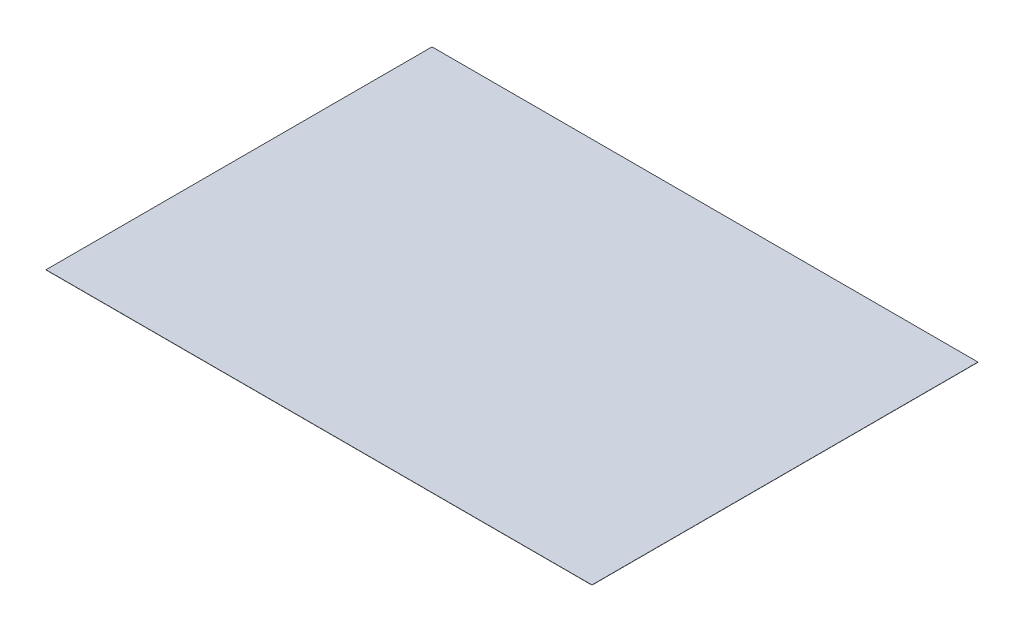
from build123d import *

# Parameters (mm, degrees)
SKETCH_1_W      = 297
SKETCH_1_H      = 210
EXTRUDE_1_DEPTH = 0.1


with BuildPart() as part:
    # 草图1 → 凸台-拉伸1 (new body)
    with BuildSketch(Plane(origin=(0, 0, 0), x_dir=(1, 0, 0), z_dir=(0, 1, 0))):
        with Locations((148.5, 105)):
            Rectangle(SKETCH_1_W, SKETCH_1_H)
    extrude(amount=EXTRUDE_1_DEPTH)


solid = part.part
